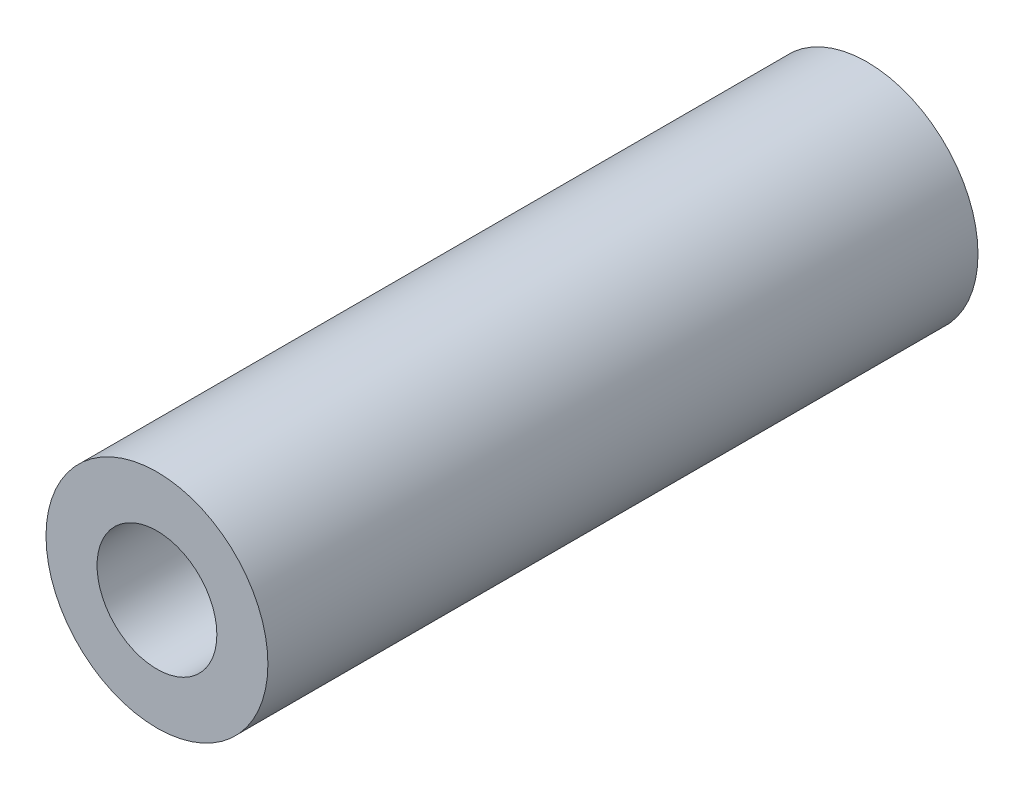
from build123d import *

# Parameters (mm, degrees)
ESQUISSE1_R        = 2.5
ESQUISSE1_R_2      = 1.35
BOSS_EXTRU_1_DEPTH = 16


with BuildPart() as part:
    # Esquisse1 → Boss.-Extru.1 (new body)
    with BuildSketch(Plane.XY):
        Circle(ESQUISSE1_R)
        Circle(ESQUISSE1_R_2, mode=Mode.SUBTRACT)
    extrude(amount=BOSS_EXTRU_1_DEPTH)


solid = part.part
